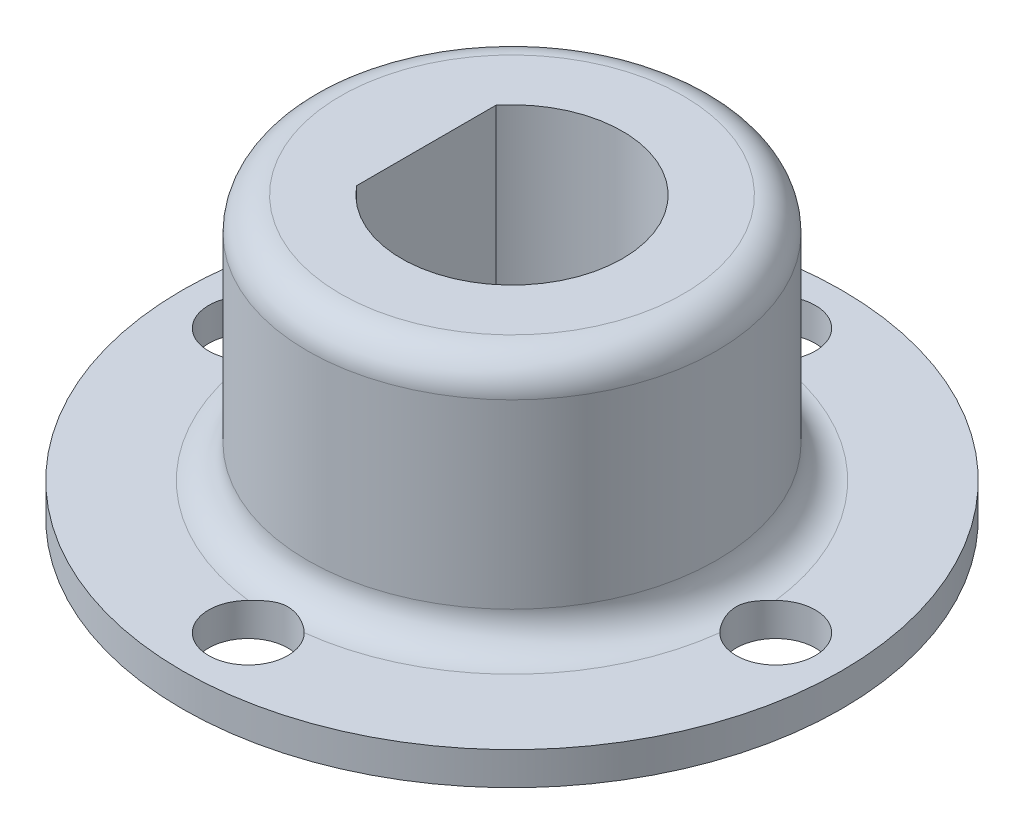
from build123d import *

# Parameters (mm, degrees)
CUT_EXTRUDE1_DEPTH   = 10
FILLET1_R            = 1
M2_CLEARANCE_HOLE2_D = 2.4
CIRPATTERN1_COUNT    = 4


with BuildPart() as part:
    # Sketch2 → Revolve1 (revolve)
    with BuildSketch(Plane.XY):
        Polygon((0, 0), (0, 8.5), (-6.2, 8.5), (-6.2, 1), (-10, 1), (-10, 0), align=None)
    revolve(axis=Axis((0, 0, 0), (0, 1, 0)))

    # Sketch3 → Cut-Extrude1 (cut)
    with BuildSketch(Plane(origin=(0, 8.5, 0), x_dir=(1, 0, 0), z_dir=(0, 1, 0))):
        with BuildLine():
            Line((-2.6, 2.112463017), (-2.6, -2.112463017))
            ThreePointArc((-2.6, -2.112463017), (3.35, 0), (-2.6, 2.112463017))
        make_face()
    extrude(amount=-CUT_EXTRUDE1_DEPTH, mode=Mode.SUBTRACT)

    # Fillet1
    fillet1_edges = [part.edges().sort_by_distance(p)[0] for p in [
        (6.2, 1, 0),
        (6.2, 8.5, 0),
    ]]
    fillet(fillet1_edges, radius=FILLET1_R)

    # M2 Clearance Hole2 (through all)
    with Locations(Plane(origin=(0, 0, 0), x_dir=(-1, 0, 0), z_dir=(0, -1, 0))):
        with Locations((8, 0)):
            m2_clearance_hole2 = Hole(M2_CLEARANCE_HOLE2_D / 2)

    # CirPattern1: M2 Clearance Hole2 ×4 about axis
    cirpattern1_axis = Axis((0, 0, 0), (0, 1, 0))
    for i in range(1, CIRPATTERN1_COUNT):
        add(m2_clearance_hole2.rotate(cirpattern1_axis, i * 360 / CIRPATTERN1_COUNT), mode=Mode.SUBTRACT)


solid = part.part
